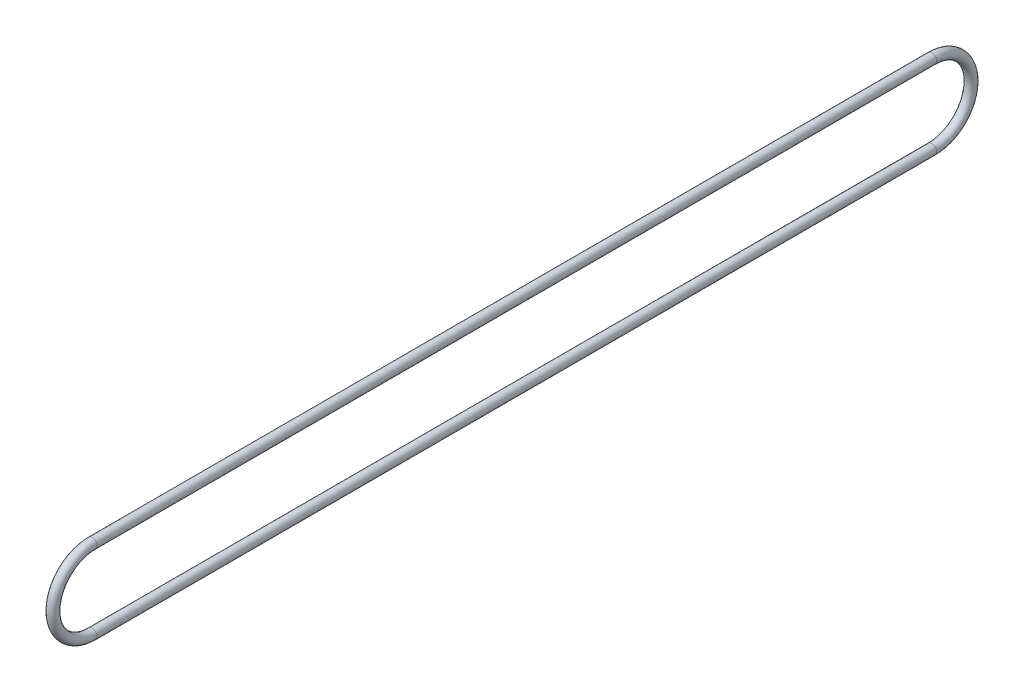
from build123d import *

# Parameters (mm, degrees)
SKETCH2_R = 1.5875


with BuildPart() as part:
    # Sweep1: sweep along a path in Sketch1
    with BuildLine(Plane(origin=(0, 0, 0), x_dir=(0, 0, -1), z_dir=(1, 0, 0))) as sweep1_path:
        Line((0, 12.7), (271.4625, 12.7))
        ThreePointArc((271.4625, 12.7), (284.1625, 0), (271.4625, -12.7))
        Line((271.4625, -12.7), (0, -12.7))
        ThreePointArc((0, -12.7), (-12.7, 0), (0, 12.7))
    # Sketch2 → Sweep1 (sweep)
    with BuildSketch(Plane.XY):
        with Locations((0, 12.7)):
            Circle(SKETCH2_R)
    sweep(path=sweep1_path.line)


solid = part.part
